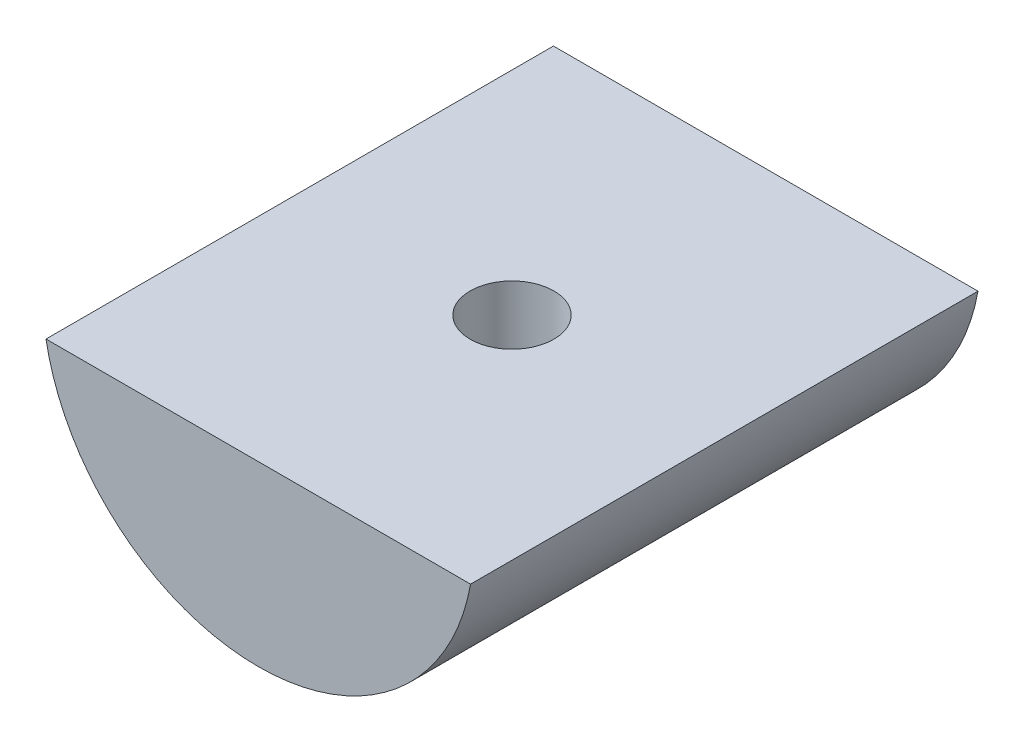
from build123d import *

# Parameters (mm, degrees)
BOSS_EXTRUDE1_DEPTH = 20
SKETCH2_R           = 1.65
CUT_EXTRUDE1_DEPTH  = 8


with BuildPart() as part:
    # Sketch1 → Boss-Extrude1 (new body)
    with BuildSketch(Plane.XY):
        with BuildLine():
            Line((-8.366600265, -1.5), (8.366600265, -1.5))
            ThreePointArc((8.366600265, -1.5), (0, -8.5), (-8.366600265, -1.5))
        make_face()
    extrude(amount=BOSS_EXTRUDE1_DEPTH)

    # Sketch2 → Cut-Extrude1 (cut, through all)
    with BuildSketch(Plane(origin=(0, -1.5, 0), x_dir=(1, 0, 0), z_dir=(0, 1, 0))):
        with Locations((0, -10)):
            Circle(SKETCH2_R)
    extrude(amount=-CUT_EXTRUDE1_DEPTH, mode=Mode.SUBTRACT)


solid = part.part
